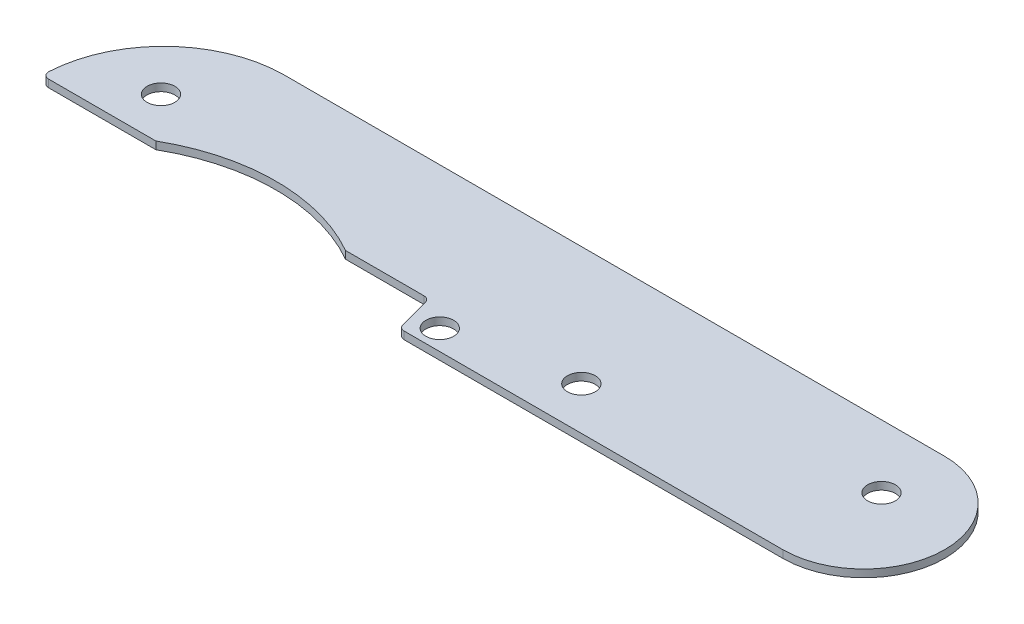
from build123d import *

# Parameters (mm, degrees)
BOSS_EXTRUDE1_DEPTH         = 0.762
F_3_8_0_11_DIAMETER_HOLE1_D = 2.794
FILLET1_R                   = 0.635


with BuildPart() as part:
    # Sketch1 → Boss-Extrude1 (new body)
    with BuildSketch(Plane(origin=(0, 0, 0), x_dir=(1, 0, 0), z_dir=(0, 1, 0))):
        with BuildLine():
            Line((0, 8.128), (-66.294, 8.128))
            ThreePointArc((-66.294, 8.128), (-74.915045876, 4.557045876), (-78.486, -4.064))
            Line((-78.486, -4.064), (-67.056, -4.064))
            ThreePointArc((-67.056, -4.064), (-57.531, -1.524), (-48.006, -4.064))
            Line((-48.006, -4.064), (-39.624, -4.064))
            Line((-39.624, -4.064), (-38.535054482, -8.128))
            Line((-38.535054482, -8.128), (0, -8.128))
            ThreePointArc((0, -8.128), (8.128, 0), (0, 8.128))
        make_face()
    extrude(amount=BOSS_EXTRUDE1_DEPTH)

    # 3/8 (0.11) Diameter Hole1 (through all)
    with Locations(Plane(origin=(0, 0.762, 0), x_dir=(1, 0, 0), z_dir=(0, 1, 0))):
        with Locations((-70.866, 0.254), (-36.503054482, -6.096), (-24.565054482, -3.81), (0, 1.778)):
            Hole(F_3_8_0_11_DIAMETER_HOLE1_D / 2)

    # Fillet1
    fillet1_edges = [part.edges().sort_by_distance(p)[0] for p in [
        (-38.535054482, 0.381, 8.128),
        (-39.624, 0.381, 4.064),
        (-78.486, 0.381, 4.064),
    ]]
    fillet(fillet1_edges, radius=FILLET1_R)


solid = part.part
